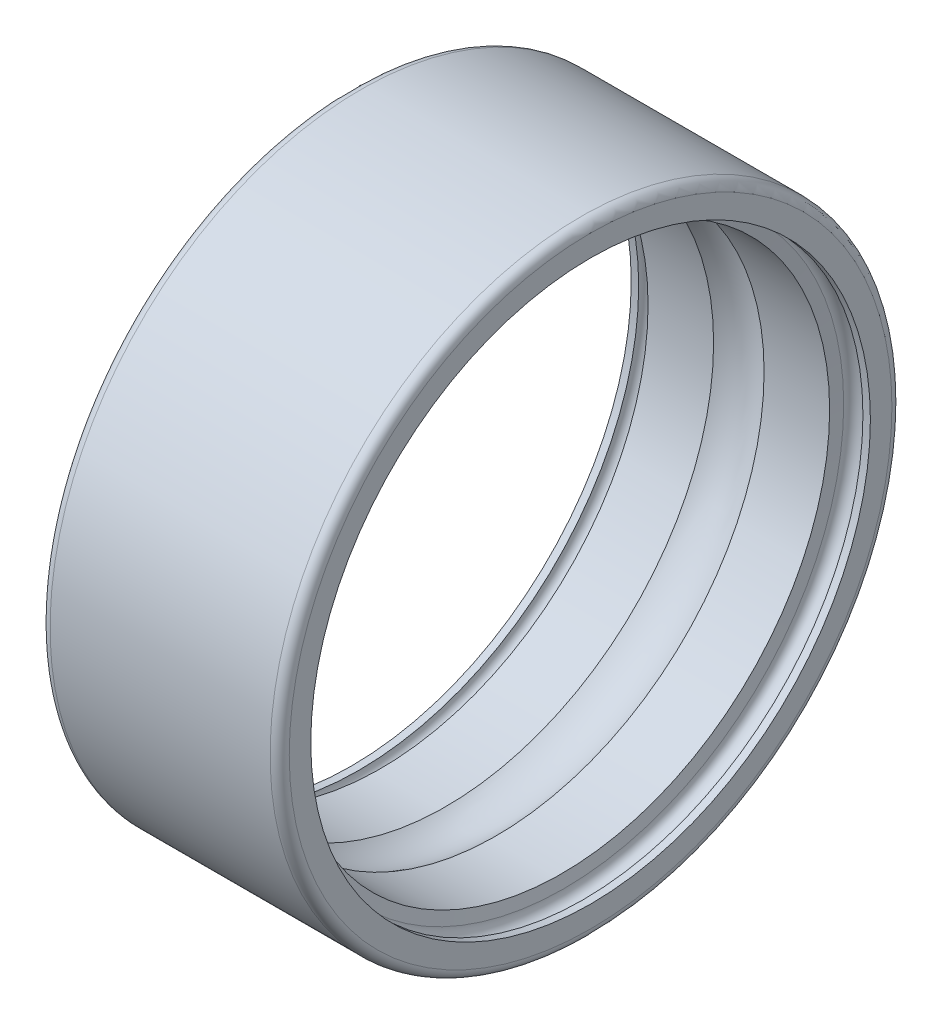
from build123d import *


with BuildPart() as part:
    # Sketch1 → Revolve1 (revolve)
    with BuildSketch(Plane.XY):
        with BuildLine():
            Line((0, 5.85), (0.156, 5.85))
            ThreePointArc((0.156, 5.85), (0.357, 6.051), (0.558, 5.85))
            Line((0.558, 5.85), (0.602081745, 5.6))
            Line((0.602081745, 5.6), (1.972303117, 5.6))
            ThreePointArc((1.972303117, 5.6), (2.5, 5.752), (3.027696883, 5.6))
            Line((3.027696883, 5.6), (4.397918255, 5.6))
            Line((4.397918255, 5.6), (4.442, 5.85))
            ThreePointArc((4.442, 5.85), (4.643, 6.051), (4.844, 5.85))
            Line((4.844, 5.85), (5, 5.85))
            Line((5, 5.85), (5, 6.3))
            ThreePointArc((5, 6.3), (4.941421356, 6.441421356), (4.8, 6.5))
            Line((4.8, 6.5), (0.2, 6.5))
            ThreePointArc((0.2, 6.5), (0.058578644, 6.441421356), (0, 6.3))
            Line((0, 6.3), (0, 5.85))
        make_face()
    revolve(axis=Axis((4.8, 0, 0), (-1, 0, 0)))


solid = part.part
